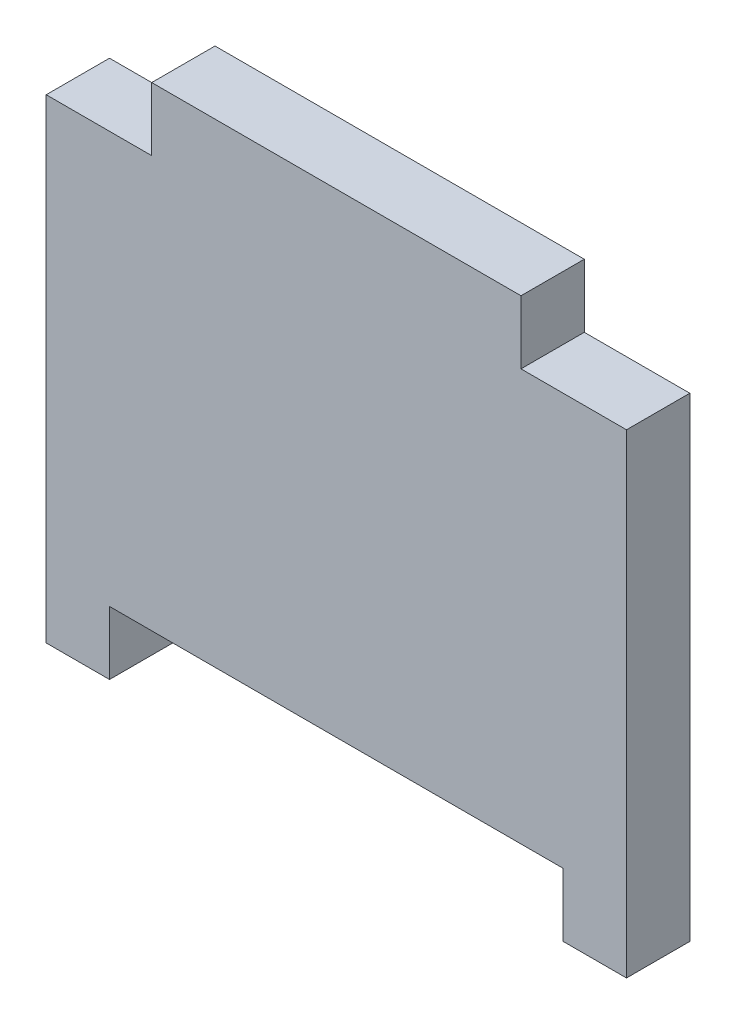
from build123d import *

# Parameters (mm, degrees)
BOSS_EXTRUDE1_DEPTH = 6
SKETCH2_W           = 10
SKETCH2_H           = 6
CUT_EXTRUDE1_DEPTH  = 6


with BuildPart() as part:
    # Sketch1 → Boss-Extrude1 (new body)
    with BuildSketch(Plane.XY):
        Polygon((-6, 0), (0, 0), (0, 51), (-55, 51), (-55, 0), (-49, 0), (-49, 6), (-6, 6), align=None)
    extrude(amount=BOSS_EXTRUDE1_DEPTH)

    # Sketch2 → Cut-Extrude1 (cut)
    with BuildSketch(Plane.XY.offset(6)):
        with Locations((-50, 48)):
            Rectangle(SKETCH2_W, SKETCH2_H)
        with Locations((-5, 48)):
            Rectangle(SKETCH2_W, SKETCH2_H)
    extrude(amount=-CUT_EXTRUDE1_DEPTH, mode=Mode.SUBTRACT)


solid = part.part
